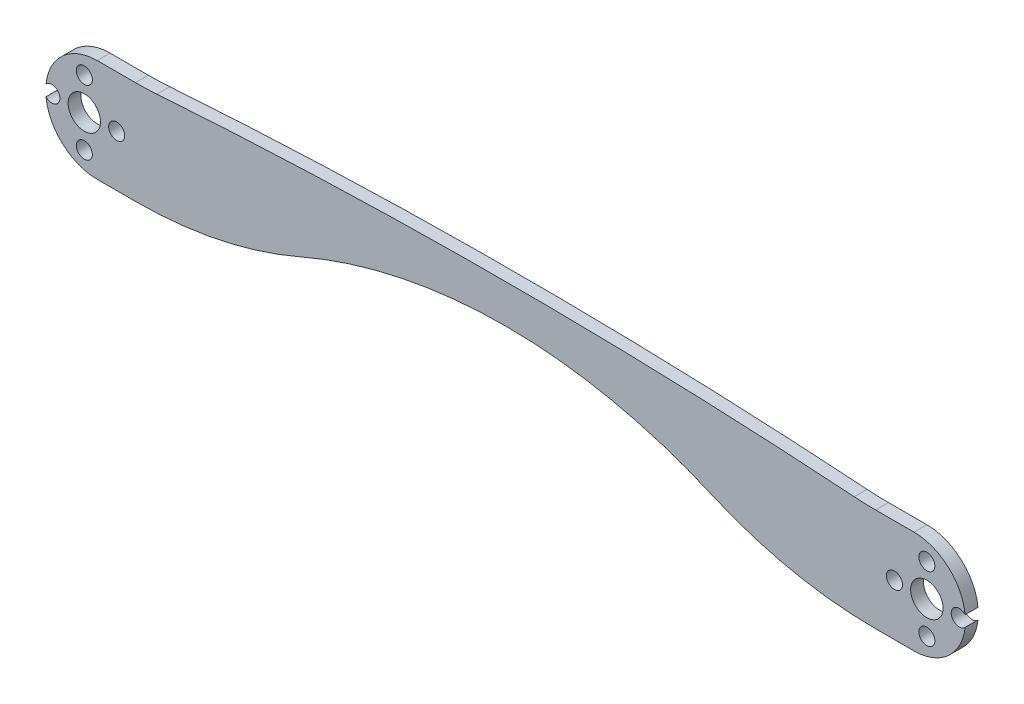
from build123d import *

# Parameters (mm, degrees)
BOSS_EXTRUDE1_DEPTH = 3.175
SKETCH3_R           = 1.984375
SKETCH3_R_2         = 4
CUT_EXTRUDE1_DEPTH  = 4.175


with BuildPart() as part:
    # Sketch2 → Boss-Extrude1 (new body)
    with BuildSketch(Plane.XY):
        with BuildLine():
            Line((0, 12.7), (9.464409507, 12.7))
            ThreePointArc((9.464409507, 12.7), (12.110944898, 12.745972855), (14.754286883, 12.883835947))
            ThreePointArc((14.754286883, 12.883835947), (100.825000026, 15.875), (186.895713169, 12.883835947))
            ThreePointArc((186.895713169, 12.883835947), (189.539055154, 12.745972855), (192.185590545, 12.7))
            Line((192.185590545, 12.7), (201.650000052, 12.7))
            ThreePointArc((201.650000052, 12.7), (214.350000052, 0), (201.650000052, -12.7))
            Line((201.650000052, -12.7), (192.185590545, -12.7))
            ThreePointArc((192.185590545, -12.7), (171.44657739, -10.560813054), (151.580883648, -4.233333333))
            ThreePointArc((151.580883648, -4.233333333), (100.825000026, 6.35), (50.069116404, -4.233333333))
            ThreePointArc((50.069116404, -4.233333333), (30.203422662, -10.560813054), (9.464409507, -12.7))
            Line((9.464409507, -12.7), (0, -12.7))
            ThreePointArc((0, -12.7), (-12.7, 0), (0, 12.7))
        make_face()
    extrude(amount=BOSS_EXTRUDE1_DEPTH)

    # Sketch3 → Cut-Extrude1 (cut, through all)
    with BuildSketch(Plane.XY.offset(3.175)):
        with Locations((-3.175, 8)):
            Circle(SKETCH3_R)
        with Locations((-3.175, 0)):
            Circle(SKETCH3_R_2)
        with Locations((204.825000052, 0)):
            Circle(SKETCH3_R_2)
        with Locations((204.825000052, 8)):
            Circle(SKETCH3_R)
        with Locations((212.825000052, 0)):
            Circle(SKETCH3_R)
        with Locations((204.825000052, -8)):
            Circle(SKETCH3_R)
        with Locations((196.825000052, 0)):
            Circle(SKETCH3_R)
        with Locations((4.825, 0)):
            Circle(SKETCH3_R)
        with Locations((-3.175, -8)):
            Circle(SKETCH3_R)
        with Locations((-11.175, 0)):
            Circle(SKETCH3_R)
    extrude(amount=-CUT_EXTRUDE1_DEPTH, mode=Mode.SUBTRACT)


solid = part.part
